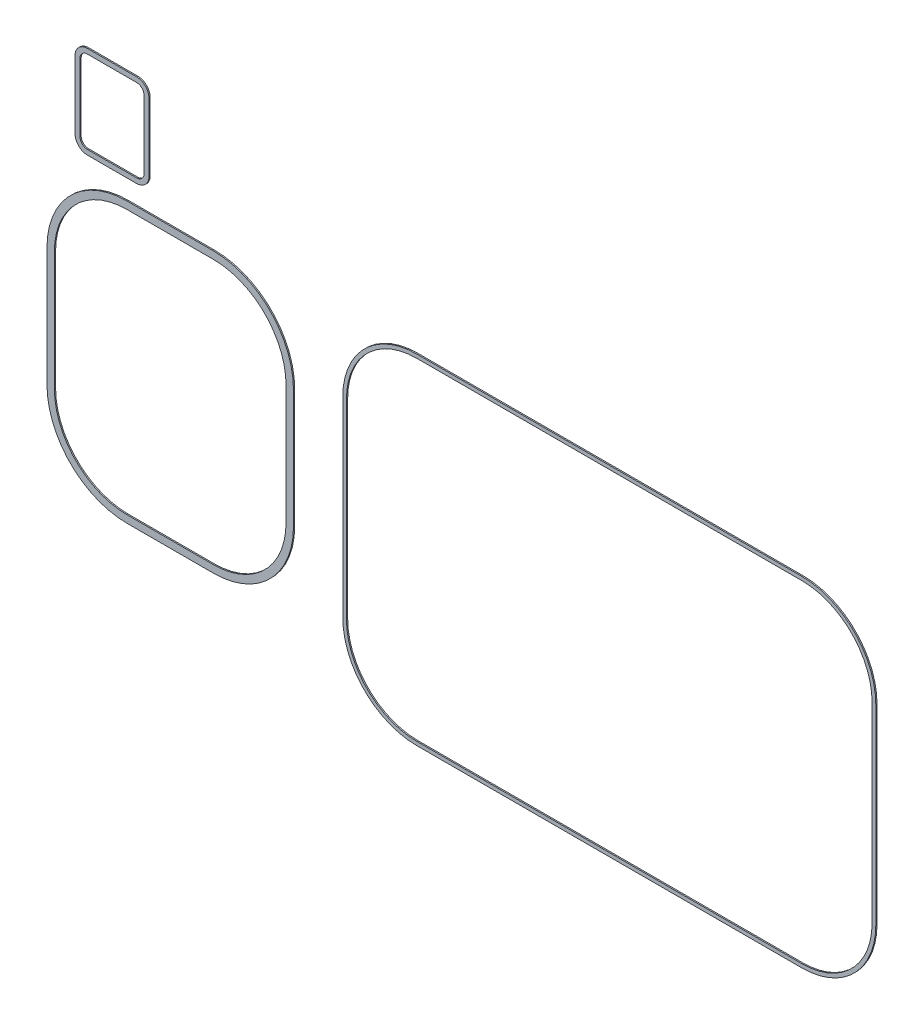
from build123d import *

# Parameters (mm, degrees)
EXTRUDE1_DEPTH   = 200
EXTRUDE1_2_DEPTH = 200
EXTRUDE1_3_DEPTH = 200


with BuildPart() as part:
    # Sketch1 → Extrude1 (new body)
    with BuildSketch(Plane.XY):
        with BuildLine():
            Line((49145.057737679, 46139.633625626), (111645.057737679, 46139.633625626))
            ThreePointArc((111645.057737679, 46139.633625626), (120130.339111917, 42624.914999864), (123645.057737679, 34139.633625626))
            Line((123645.057737679, 34139.633625626), (123645.057737679, 3109.633625626))
            ThreePointArc((123645.057737679, 3109.633625626), (120130.339111917, -5375.647748613), (111645.057737679, -8890.366374374))
            Line((111645.057737679, -8890.366374374), (49145.057737679, -8890.366374374))
            ThreePointArc((49145.057737679, -8890.366374374), (40659.77636344, -5375.647748613), (37145.057737679, 3109.633625626))
            Line((37145.057737679, 3109.633625626), (37145.057737679, 34139.633625626))
            ThreePointArc((37145.057737679, 34139.633625626), (40659.77636344, 42624.914999864), (49145.057737679, 46139.633625626))
        make_face()
        with BuildLine():
            Line((123045.057737679, 34139.633625626), (123045.057737679, 3109.633625626))
            ThreePointArc((123045.057737679, 3109.633625626), (119706.075043205, -4951.383679901), (111645.057737679, -8290.366374374))
            Line((111645.057737679, -8290.366374374), (49145.057737679, -8290.366374374))
            ThreePointArc((49145.057737679, -8290.366374374), (41084.040432152, -4951.383679901), (37745.057737679, 3109.633625626))
            Line((37745.057737679, 3109.633625626), (37745.057737679, 34139.633625626))
            ThreePointArc((37745.057737679, 34139.633625626), (41084.040432152, 42200.650931152), (49145.057737679, 45539.633625626))
            Line((49145.057737679, 45539.633625626), (111645.057737679, 45539.633625626))
            ThreePointArc((111645.057737679, 45539.633625626), (119706.075043205, 42200.650931152), (123045.057737679, 34139.633625626))
        make_face(mode=Mode.SUBTRACT)
    extrude(amount=-EXTRUDE1_DEPTH)


with BuildPart() as body_2:
    # Sketch1 → Extrude1 2 (new body)
    with BuildSketch(Plane.XY):
        with BuildLine():
            Line((2145.057737679, 44139.633625626), (16145.057737679, 44139.633625626))
            ThreePointArc((16145.057737679, 44139.633625626), (25337.445893104, 40332.021781051), (29145.057737679, 31139.633625626))
            Line((29145.057737679, 31139.633625626), (29145.057737679, 11839.633625626))
            ThreePointArc((29145.057737679, 11839.633625626), (25337.445893104, 2647.245470201), (16145.057737679, -1160.366374374))
            Line((16145.057737679, -1160.366374374), (2145.057737679, -1160.366374374))
            ThreePointArc((2145.057737679, -1160.366374374), (-7047.330417747, 2647.245470201), (-10854.942262321, 11839.633625626))
            Line((-10854.942262321, 11839.633625626), (-10854.942262321, 31139.633625626))
            ThreePointArc((-10854.942262321, 31139.633625626), (-7047.330417747, 40332.021781051), (2145.057737679, 44139.633625626))
        make_face()
        with BuildLine():
            Line((27945.057737679, 31139.633625626), (27945.057737679, 11839.633625626))
            ThreePointArc((27945.057737679, 11839.633625626), (24488.91775568, 3495.773607624), (16145.057737679, 39.633625626))
            Line((16145.057737679, 39.633625626), (2145.057737679, 39.633625626))
            ThreePointArc((2145.057737679, 39.633625626), (-6198.802280323, 3495.773607624), (-9654.942262321, 11839.633625626))
            Line((-9654.942262321, 11839.633625626), (-9654.942262321, 31139.633625626))
            ThreePointArc((-9654.942262321, 31139.633625626), (-6198.802280323, 39483.493643627), (2145.057737679, 42939.633625626))
            Line((2145.057737679, 42939.633625626), (16145.057737679, 42939.633625626))
            ThreePointArc((16145.057737679, 42939.633625626), (24488.91775568, 39483.493643627), (27945.057737679, 31139.633625626))
        make_face(mode=Mode.SUBTRACT)
    extrude(amount=-EXTRUDE1_2_DEPTH)


with BuildPart() as body_3:
    # Sketch1 → Extrude1 3 (new body)
    with BuildSketch(Plane.XY):
        with BuildLine():
            Line((3698.999542599, 62369.727650707), (-4301.000457401, 62369.727650707))
            ThreePointArc((-4301.000457401, 62369.727650707), (-5715.214019774, 61783.941213081), (-6301.000457401, 60369.727650707))
            Line((-6301.000457401, 60369.727650707), (-6301.000457401, 49369.727650707))
            ThreePointArc((-6301.000457401, 49369.727650707), (-5715.214019774, 47955.514088334), (-4301.000457401, 47369.727650707))
            Line((-4301.000457401, 47369.727650707), (3698.999542599, 47369.727650707))
            ThreePointArc((3698.999542599, 47369.727650707), (5113.213104972, 47955.514088334), (5698.999542599, 49369.727650707))
            Line((5698.999542599, 49369.727650707), (5698.999542599, 60369.727650707))
            ThreePointArc((5698.999542599, 60369.727650707), (5113.213104972, 61783.941213081), (3698.999542599, 62369.727650707))
        make_face()
        with BuildLine():
            Line((-5501.000457401, 60369.727650707), (-5501.000457401, 49369.727650707))
            ThreePointArc((-5501.000457401, 49369.727650707), (-5149.528594825, 48521.199513284), (-4301.000457401, 48169.727650707))
            Line((-4301.000457401, 48169.727650707), (3698.999542599, 48169.727650707))
            ThreePointArc((3698.999542599, 48169.727650707), (4547.527680023, 48521.199513284), (4898.999542599, 49369.727650707))
            Line((4898.999542599, 49369.727650707), (4898.999542599, 60369.727650707))
            ThreePointArc((4898.999542599, 60369.727650707), (4547.527680023, 61218.255788131), (3698.999542599, 61569.727650707))
            Line((3698.999542599, 61569.727650707), (-4301.000457401, 61569.727650707))
            ThreePointArc((-4301.000457401, 61569.727650707), (-5149.528594825, 61218.255788131), (-5501.000457401, 60369.727650707))
        make_face(mode=Mode.SUBTRACT)
    extrude(amount=-EXTRUDE1_3_DEPTH)


solid = Compound([part.part, body_2.part, body_3.part])
